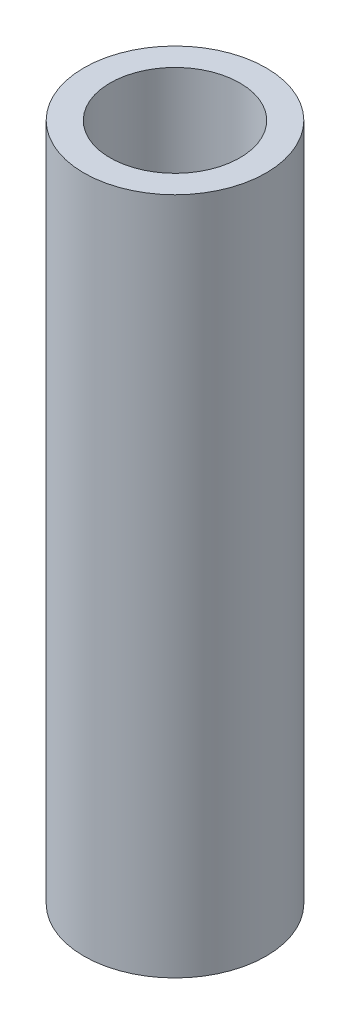
from build123d import *

# Parameters (mm, degrees)
SKETCH2_R           = 9.279861491
SKETCH2_R_2         = 6.60908
BOSS_EXTRUDE1_DEPTH = 69.088


with BuildPart() as part:
    # Sketch2 → Boss-Extrude1 (new body)
    with BuildSketch(Plane.XZ):
        Circle(SKETCH2_R)
        Circle(SKETCH2_R_2, mode=Mode.SUBTRACT)
    extrude(amount=BOSS_EXTRUDE1_DEPTH)


solid = part.part
